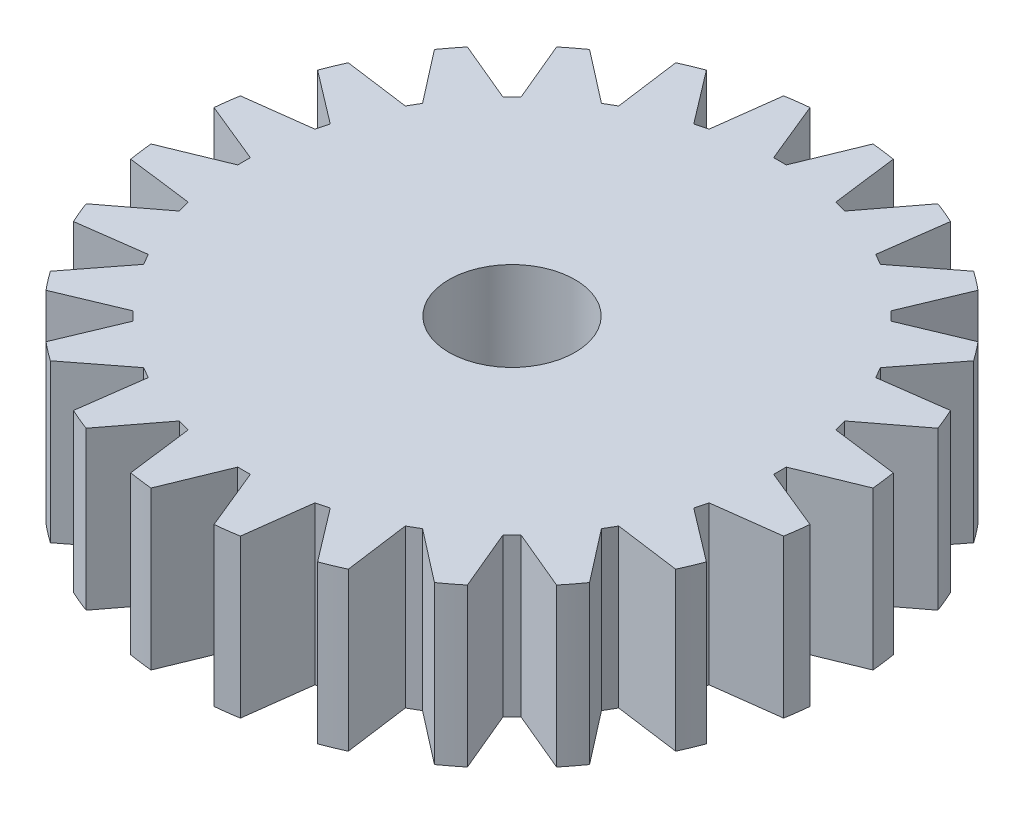
from build123d import *

# Parameters (mm, degrees)
SKETCH1_R           = 10.5
BOSS_EXTRUDE1_DEPTH = 5
SKETCH2_R           = 2
CUT_EXTRUDE1_DEPTH  = 6
CUT_EXTRUDE2_DEPTH  = 5
CIRPATTERN1_COUNT   = 24


with BuildPart() as part:
    # Sketch1 → Boss-Extrude1 (new body)
    with BuildSketch(Plane(origin=(0, 0, 0), x_dir=(1, 0, 0), z_dir=(0, 1, 0))):
        Circle(SKETCH1_R)
    extrude(amount=BOSS_EXTRUDE1_DEPTH)

    # Sketch2 → Cut-Extrude1 (cut, through all)
    with BuildSketch(Plane(origin=(0, 5, 0), x_dir=(1, 0, 0), z_dir=(0, 1, 0))):
        Circle(SKETCH2_R)
    extrude(amount=-CUT_EXTRUDE1_DEPTH, mode=Mode.SUBTRACT)

    # Sketch3 → Cut-Extrude2 (cut)
    with BuildSketch(Plane(origin=(0, 5, 0), x_dir=(1, 0, 0), z_dir=(0, 1, 0))):
        Polygon((0, 8.5), (0.2, 8.5), (1, 10.45227248), (1, 11.821377403), (-1, 11.821377403), (-1, 10.45227248), (-0.2, 8.5), align=None)
    cut_extrude2 = extrude(amount=-CUT_EXTRUDE2_DEPTH, mode=Mode.SUBTRACT)

    # CirPattern1: Cut-Extrude2 ×24 about axis
    cirpattern1_axis = Axis((0, 0, 0), (0, 1, 0))
    for i in range(1, CIRPATTERN1_COUNT):
        add(cut_extrude2.rotate(cirpattern1_axis, i * 360 / CIRPATTERN1_COUNT), mode=Mode.SUBTRACT)


solid = part.part
